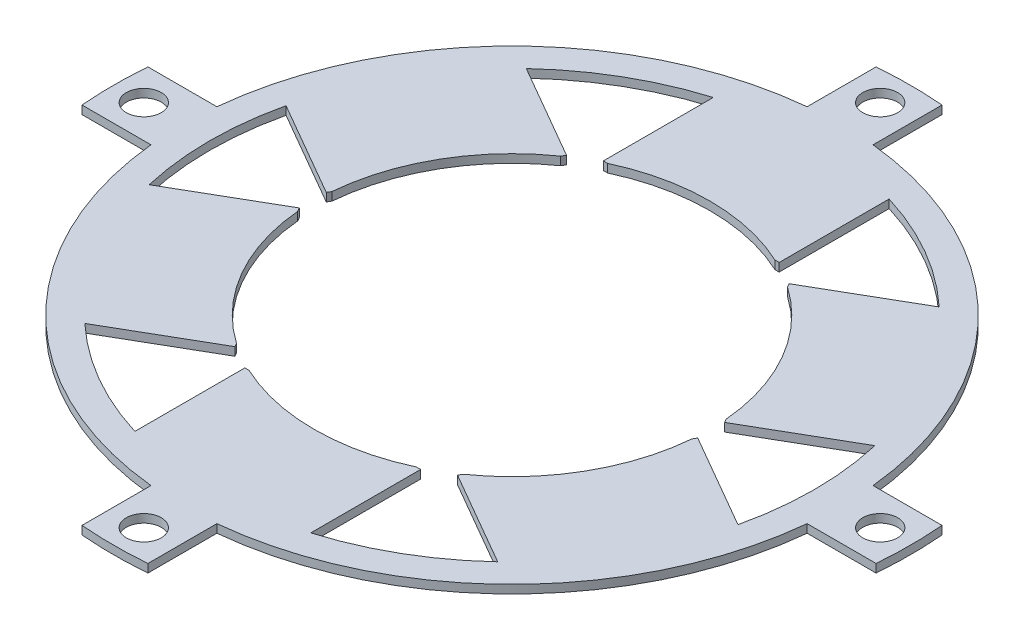
from build123d import *

# Parameters (mm, degrees)
SKETCH1_R           = 3.175
BOSS_EXTRUDE5_DEPTH = 1.52
SKETCH3_R           = 36
CUT_EXTRUDE4_DEPTH  = 2.52


with BuildPart() as part:
    # Sketch1 → Boss-Extrude5 (new body)
    with BuildSketch(Plane(origin=(0, 0, 0), x_dir=(1, 0, 0), z_dir=(0, 1, 0))):
        with BuildLine():
            Line((-5.999999832, 72.25129758), (-5.999999832, 59.699246243))
            ThreePointArc((-5.999999832, 59.699246243), (-42.426406812, 42.426406931), (-59.699246226, 6))
            Line((-59.699246226, 6), (-72.251297552, 6.000000168))
            ThreePointArc((-72.251297552, 6.000000168), (-72.5, 1.68e-07), (-72.25129758, -5.999999832))
            Line((-72.25129758, -5.999999832), (-59.699246243, -5.999999832))
            ThreePointArc((-59.699246243, -5.999999832), (-42.426406931, -42.426406812), (-6, -59.699246226))
            Line((-6, -59.699246226), (-6.000000168, -72.251297552))
            ThreePointArc((-6.000000168, -72.251297552), (-1.68e-07, -72.5), (5.999999832, -72.25129758))
            Line((5.999999832, -72.25129758), (5.999999832, -59.699246243))
            ThreePointArc((5.999999832, -59.699246243), (42.426406812, -42.426406931), (59.699246226, -6))
            Line((59.699246226, -6), (72.251297552, -6.000000168))
            ThreePointArc((72.251297552, -6.000000168), (72.5, -1.68e-07), (72.25129758, 5.999999832))
            Line((72.25129758, 5.999999832), (59.699246243, 5.999999832))
            ThreePointArc((59.699246243, 5.999999832), (42.426406931, 42.426406812), (6, 59.699246226))
            Line((6, 59.699246226), (6.000000168, 72.251297552))
            ThreePointArc((6.000000168, 72.251297552), (1.68e-07, 72.5), (-5.999999832, 72.25129758))
        make_face()
        with Locations((9.7e-08, 67)):
            Circle(SKETCH1_R, mode=Mode.SUBTRACT)
        with Locations((67, -9.7e-08)):
            Circle(SKETCH1_R, mode=Mode.SUBTRACT)
        with Locations((-9.7e-08, -67)):
            Circle(SKETCH1_R, mode=Mode.SUBTRACT)
        with Locations((-67, 9.7e-08)):
            Circle(SKETCH1_R, mode=Mode.SUBTRACT)
        with BuildLine():
            Line((20.250864517, 30.167050694), (37.571372593, 40.167050694))
            ThreePointArc((37.571372593, 40.167050694), (27.5, 47.631397208), (16, 52.621288468))
            Line((16, 52.621288468), (16, 32.621288468))
            Line((16, 32.621288468), (-16, 32.621288468))
            Line((-16, 32.621288468), (-16, 52.621288468))
            ThreePointArc((-16, 52.621288468), (-27.5, 47.631397208), (-37.571372593, 40.167050694))
            Line((-37.571372593, 40.167050694), (-20.250864517, 30.167050694))
            Line((-20.250864517, 30.167050694), (-36.250864517, 2.454237773))
            Line((-36.250864517, 2.454237773), (-53.571372593, 12.454237773))
            ThreePointArc((-53.571372593, 12.454237773), (-55, 0), (-53.571372593, -12.454237773))
            Line((-53.571372593, -12.454237773), (-36.250864517, -2.454237773))
            Line((-36.250864517, -2.454237773), (-20.250864517, -30.167050694))
            Line((-20.250864517, -30.167050694), (-37.571372593, -40.167050694))
            ThreePointArc((-37.571372593, -40.167050694), (-27.5, -47.631397208), (-16, -52.621288468))
            Line((-16, -52.621288468), (-16, -32.621288468))
            Line((-16, -32.621288468), (16, -32.621288468))
            Line((16, -32.621288468), (16, -52.621288468))
            ThreePointArc((16, -52.621288468), (27.5, -47.631397208), (37.571372593, -40.167050694))
            Line((37.571372593, -40.167050694), (20.250864517, -30.167050694))
            Line((20.250864517, -30.167050694), (36.250864517, -2.454237773))
            Line((36.250864517, -2.454237773), (53.571372593, -12.454237773))
            ThreePointArc((53.571372593, -12.454237773), (55, 0), (53.571372593, 12.454237773))
            Line((53.571372593, 12.454237773), (36.250864517, 2.454237773))
            Line((36.250864517, 2.454237773), (20.250864517, 30.167050694))
        make_face(mode=Mode.SUBTRACT)
    extrude(amount=BOSS_EXTRUDE5_DEPTH)

    # Sketch3 → Cut-Extrude4 (cut, through all)
    with BuildSketch(Plane(origin=(0, 0, 0), x_dir=(1, 0, 0), z_dir=(0, 1, 0))):
        Circle(SKETCH3_R)
    extrude(amount=CUT_EXTRUDE4_DEPTH, mode=Mode.SUBTRACT)


solid = part.part
